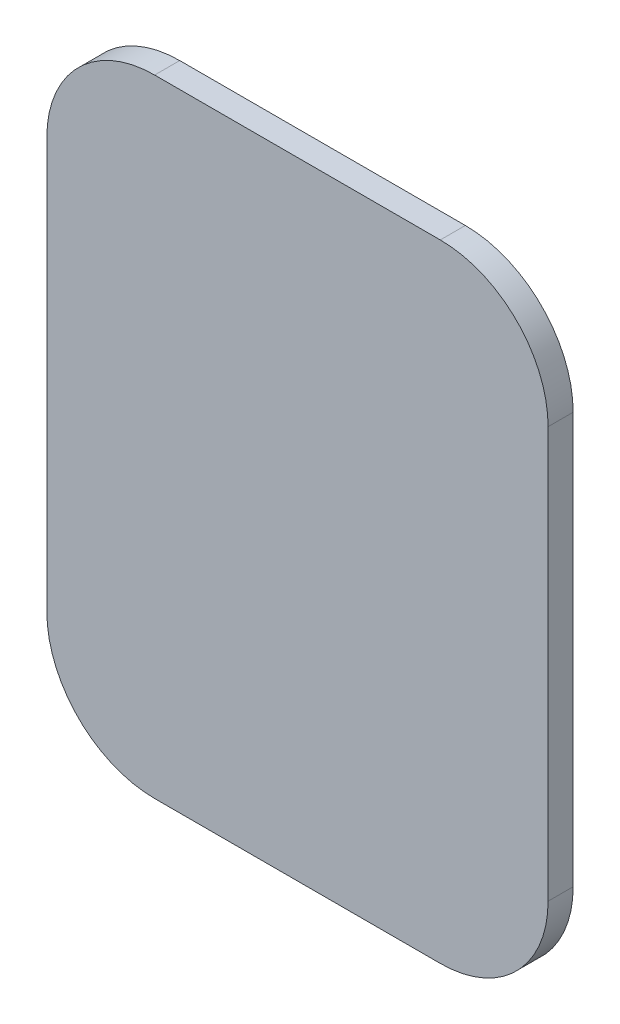
from build123d import *

# Parameters (mm, degrees)
LANDING_PAD_2_5X2_DEPTH = 0.1


with BuildPart() as part:
    # Sketch9 → landing-pad-2.5x2 (new body)
    with BuildSketch(Plane.XY):
        with BuildLine():
            Line((1, 0.819799953), (1, -0.819799953))
            ThreePointArc((1, -0.819799953), (0.873997324, -1.123997324), (0.569799953, -1.25))
            Line((0.569799953, -1.25), (-0.569799953, -1.25))
            ThreePointArc((-0.569799953, -1.25), (-0.873997324, -1.123997324), (-1, -0.819799953))
            Line((-1, -0.819799953), (-1, 0.819799953))
            ThreePointArc((-1, 0.819799953), (-0.873997324, 1.123997324), (-0.569799953, 1.25))
            Line((-0.569799953, 1.25), (0.569799953, 1.25))
            ThreePointArc((0.569799953, 1.25), (0.873997324, 1.123997324), (1, 0.819799953))
        make_face()
    extrude(amount=-LANDING_PAD_2_5X2_DEPTH)


solid = part.part
